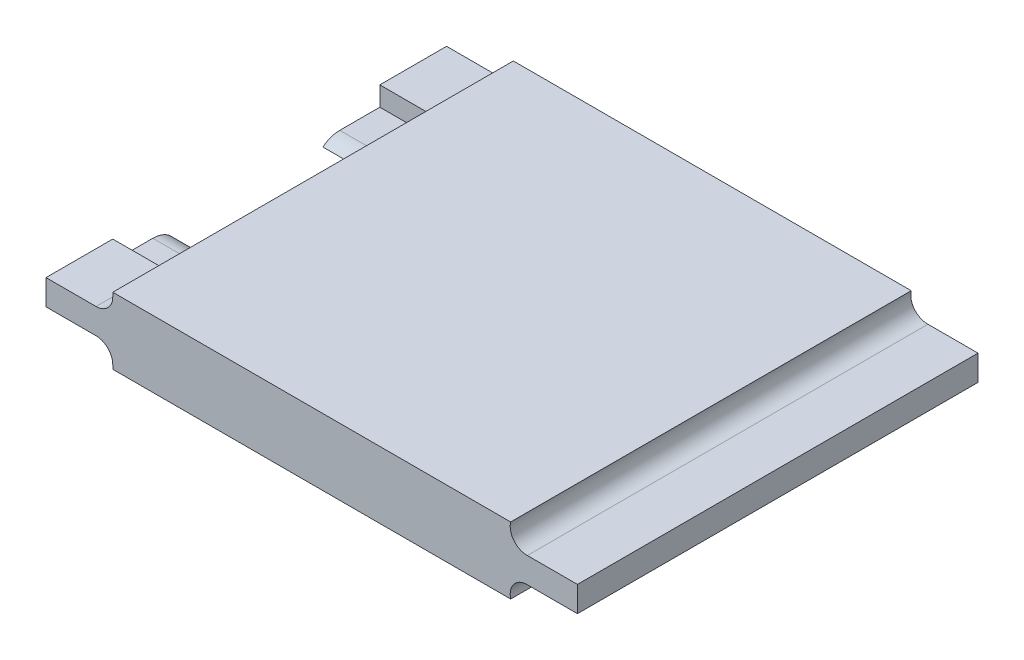
from build123d import *

# Parameters (mm, degrees)
EXTRUDE_1_DEPTH     = 60
CUT_EXTRUDE_1_DEPTH = 17.3


with BuildPart() as part:
    # 스케치1 → 보스-돌출1 (new body)
    with BuildSketch(Plane.XY):
        with BuildLine():
            Line((29.8, 10), (-29.8, 10))
            Line((-29.8, 10), (-29.8, 9.4))
            ThreePointArc((-29.8, 9.4), (-30.532233047, 7.632233047), (-32.3, 6.9))
            Line((-32.3, 6.9), (-39.8, 6.9))
            Line((-39.8, 6.9), (-39.8, 3.1))
            Line((-39.8, 3.1), (-32.3, 3.1))
            ThreePointArc((-32.3, 3.1), (-30.532233047, 2.367766953), (-29.8, 0.6))
            Line((-29.8, 0.6), (-29.8, 0))
            Line((-29.8, 0), (29.8, 0))
            ThreePointArc((29.8, 0), (30.280633401, 2.170456935), (32.3, 3.1))
            Line((32.3, 3.1), (39.8, 3.1))
            Line((39.8, 3.1), (39.8, 6.9))
            Line((39.8, 6.9), (32.3, 6.9))
            ThreePointArc((32.3, 6.9), (30.280633401, 7.829543065), (29.8, 10))
        make_face()
    extrude(amount=EXTRUDE_1_DEPTH)

    # 스케치2 → 컷-돌출1 (cut)
    with BuildSketch(Plane.ZY.offset(39.8)):
        with BuildLine():
            Line((44, 4), (50, 4))
            Line((50, 4), (50, 8))
            Line((50, 8), (10, 8))
            Line((10, 8), (10, 4))
            Line((10, 4), (16, 4))
            ThreePointArc((16, 4), (18.828427125, 2.828427125), (20, 0))
            Line((20, 0), (40, 0))
            ThreePointArc((40, 0), (41.171572875, 2.828427125), (44, 4))
        make_face()
    extrude(amount=-CUT_EXTRUDE_1_DEPTH, mode=Mode.SUBTRACT)


solid = part.part
